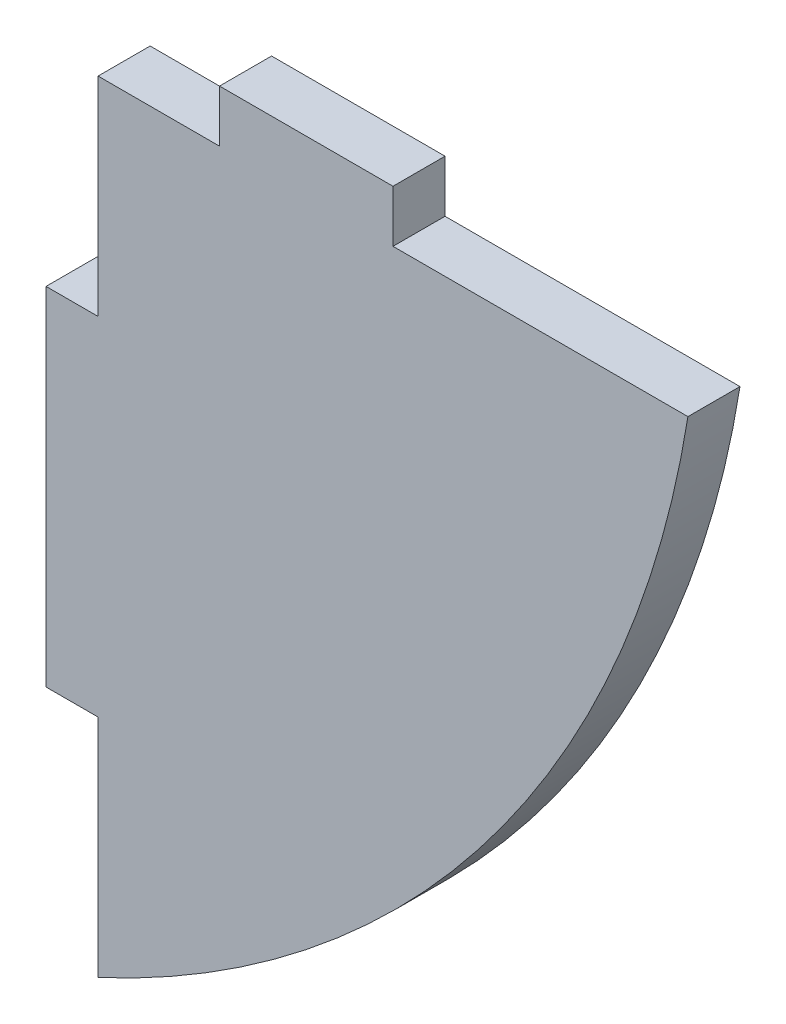
from build123d import *

# Parameters (mm, degrees)
EXTRUDE_1_DEPTH = 1.5


with BuildPart() as part:
    # 草图2 → 凸台-拉伸1 (new body, symmetric)
    with BuildSketch(Plane.XY):
        with BuildLine():
            Line((0, 45), (0, 33))
            Line((0, 33), (-3, 33))
            Line((-3, 33), (-3, 13))
            Line((-3, 13), (0, 13))
            Line((0, 13), (0, 0))
            ThreePointArc((0, 0), (22.61707334, 18.255989032), (34, 45))
            Line((34, 45), (17, 45))
            Line((17, 45), (17, 48))
            Line((17, 48), (7, 48))
            Line((7, 48), (7, 45))
            Line((7, 45), (0, 45))
        make_face()
    extrude(amount=EXTRUDE_1_DEPTH, both=True)


solid = part.part
